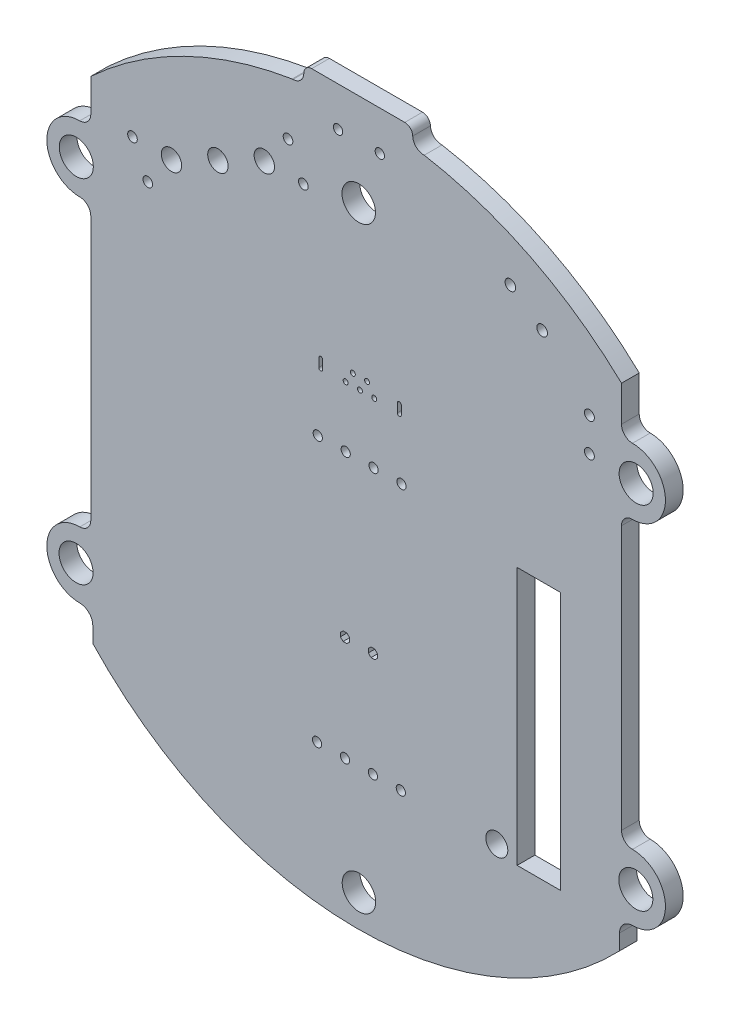
from build123d import *

# Parameters (mm, degrees)
MODEL_R             = 0.4191
MODEL_R_2           = 0.227
MODEL_R_3           = 0.482663622
MODEL_R_4           = 0.43815
MODEL_R_5           = 0.9271
MODEL_R_6           = 0.425
MODEL_R_7           = 0.45
MODEL_R_8           = 1.524
MODEL_R_9           = 1.55
MODEL_R_10          = 1
MODEL_W             = 3.937
MODEL_H             = 23.478
BOSS_EXTRUDE1_DEPTH = 1.6129


with BuildPart() as part:
    # Model → Boss-Extrude1 (new body)
    with BuildSketch(Plane.XY):
        with BuildLine():
            Line((-23.779710926, -18.809832125), (-23.779710926, -17.398832125))
            ThreePointArc((-23.779710926, -17.398832125), (-24.125617817, -16.563739016), (-24.960710926, -16.217832125))
            ThreePointArc((-24.960710926, -16.217832125), (-27.082031269, -15.339152468), (-27.960710926, -13.217832125))
            ThreePointArc((-27.960710926, -13.217832125), (-27.082031269, -11.096511781), (-24.960710926, -10.217832125))
            ThreePointArc((-24.960710926, -10.217832125), (-24.253604145, -9.924938906), (-23.960710926, -9.217832125))
            Line((-23.960710926, -9.217832125), (-23.960710926, 14.782167875))
            ThreePointArc((-23.960710926, 14.782167875), (-24.253604145, 15.489274656), (-24.960710926, 15.782167875))
            ThreePointArc((-24.960710926, 15.782167875), (-27.082031269, 16.660847532), (-27.960710926, 18.782167875))
            ThreePointArc((-27.960710926, 18.782167875), (-27.082031269, 20.903488219), (-24.960710926, 21.782167875))
            ThreePointArc((-24.960710926, 21.782167875), (-24.253604145, 22.075061094), (-23.960710926, 22.782167875))
            Line((-23.960710926, 22.782167875), (-23.960710926, 25.782167875))
            ThreePointArc((-23.960710926, 25.782167875), (-15.463875449, 31.618102481), (-5.640710926, 34.742167875))
            Line((-5.640710926, 34.742167875), (-5.560710926, 34.742167875))
            ThreePointArc((-5.560710926, 34.742167875), (-4.86774628, 35.02920323), (-4.580710926, 35.722167875))
            ThreePointArc((-4.580710926, 35.722167875), (-4.369827808, 36.231284758), (-3.860710926, 36.442167875))
            Line((-3.860710926, 36.442167875), (4.609289074, 36.442167875))
            ThreePointArc((4.609289074, 36.442167875), (5.118407802, 36.231286158), (5.32929232, 35.72216859))
            ThreePointArc((5.32929232, 35.72216859), (5.651326218, 35.014708556), (6.379288359, 34.742171121))
            ThreePointArc((6.379288359, 34.742171121), (16.019672961, 31.575717146), (24.329289074, 25.752167875))
            Line((24.329289074, 25.752167875), (24.326289074, 22.516167875))
            ThreePointArc((24.326289074, 22.516167875), (24.619182293, 21.809061094), (25.326289074, 21.516167875))
            ThreePointArc((25.326289074, 21.516167875), (27.447609418, 20.637488219), (28.326289074, 18.516167875))
            ThreePointArc((28.326289074, 18.516167875), (27.447609418, 16.394847532), (25.326289074, 15.516167875))
            ThreePointArc((25.326289074, 15.516167875), (24.619182293, 15.223274656), (24.326289074, 14.516167875))
            Line((24.326289074, 14.516167875), (24.326289074, -9.483832125))
            ThreePointArc((24.326289074, -9.483832125), (24.619182293, -10.190938906), (25.326289074, -10.483832125))
            ThreePointArc((25.326289074, -10.483832125), (27.447609418, -11.362511781), (28.326289074, -13.483832125))
            ThreePointArc((28.326289074, -13.483832125), (27.447609418, -15.605152468), (25.326289074, -16.483832125))
            ThreePointArc((25.326289074, -16.483832125), (24.491195966, -16.829739016), (24.145289074, -17.664832125))
            Line((24.145289074, -17.664832125), (24.146689074, -19.076432125))
            ThreePointArc((24.146689074, -19.076432125), (0.126168598, -29.247573474), (-23.779710926, -18.809832125))
        make_face()
        with Locations((-3.370710926, -16.372832125)):
            Circle(MODEL_R, mode=Mode.SUBTRACT)
        with Locations((-0.830710926, -16.372832125)):
            Circle(MODEL_R, mode=Mode.SUBTRACT)
        with Locations((1.709289074, -16.372832125)):
            Circle(MODEL_R, mode=Mode.SUBTRACT)
        with Locations((4.249289074, -16.372832125)):
            Circle(MODEL_R, mode=Mode.SUBTRACT)
        with Locations((4.312789074, 7.804667875)):
            Circle(MODEL_R, mode=Mode.SUBTRACT)
        with Locations((1.772789074, 7.804667875)):
            Circle(MODEL_R, mode=Mode.SUBTRACT)
        with Locations((-0.767210926, 7.804667875)):
            Circle(MODEL_R, mode=Mode.SUBTRACT)
        with Locations((-3.307210926, 7.804667875)):
            Circle(MODEL_R, mode=Mode.SUBTRACT)
        with Locations((0.530089074, 13.311767875)):
            Circle(MODEL_R_2, mode=Mode.SUBTRACT)
        with Locations((-0.119910926, 14.311767875)):
            Circle(MODEL_R_2, mode=Mode.SUBTRACT)
        with Locations((1.830089074, 13.311767875)):
            Circle(MODEL_R_2, mode=Mode.SUBTRACT)
        with Locations((1.180089074, 14.311767875)):
            Circle(MODEL_R_2, mode=Mode.SUBTRACT)
        with Locations((-0.769910926, 13.311767875)):
            Circle(MODEL_R_2, mode=Mode.SUBTRACT)
        with Locations((14.214989074, 28.432167875)):
            Circle(MODEL_R_3, mode=Mode.SUBTRACT)
        with Locations((-20.168710926, 22.918167875)):
            Circle(MODEL_R_4, mode=Mode.SUBTRACT)
        with Locations((17.107289074, 26.303367875)):
            Circle(MODEL_R_3, mode=Mode.SUBTRACT)
        with Locations((-18.776910926, 20.064467875)):
            Circle(MODEL_R_4, mode=Mode.SUBTRACT)
        with Locations((-6.014510926, 29.821667875)):
            Circle(MODEL_R_4, mode=Mode.SUBTRACT)
        with Locations((-4.622710926, 26.967967875)):
            Circle(MODEL_R_4, mode=Mode.SUBTRACT)
        with Locations((-16.619110926, 22.883167875)):
            Circle(MODEL_R_5, mode=Mode.SUBTRACT)
        with Locations((-12.395710926, 24.943067875)):
            Circle(MODEL_R_5, mode=Mode.SUBTRACT)
        with Locations((-8.172210926, 27.002967875)):
            Circle(MODEL_R_5, mode=Mode.SUBTRACT)
        with Locations((2.339289074, 32.852167875)):
            Circle(MODEL_R_6, mode=Mode.SUBTRACT)
        with Locations((-1.460710926, 32.852167875)):
            Circle(MODEL_R_6, mode=Mode.SUBTRACT)
        with Locations((21.409289074, 21.770167875)):
            Circle(MODEL_R_7, mode=Mode.SUBTRACT)
        with Locations((21.409289074, 18.734167875)):
            Circle(MODEL_R_7, mode=Mode.SUBTRACT)
        with Locations((0.419289074, 27.993767875)):
            Circle(MODEL_R_8, mode=Mode.SUBTRACT)
        with Locations((-25.280710926, 18.783767875)):
            Circle(MODEL_R_9, mode=Mode.SUBTRACT)
        with Locations((-25.300710926, -13.226232125)):
            Circle(MODEL_R_9, mode=Mode.SUBTRACT)
        with Locations((0.439289074, -26.316232125)):
            Circle(MODEL_R_8, mode=Mode.SUBTRACT)
        with Locations((25.629289074, -13.486232125)):
            Circle(MODEL_R_9, mode=Mode.SUBTRACT)
        with Locations((25.659289074, 18.523767875)):
            Circle(MODEL_R_9, mode=Mode.SUBTRACT)
        with Locations((12.982089074, -16.238232125)):
            Circle(MODEL_R_10, mode=Mode.SUBTRACT)
        with BuildLine():
            Line((-2.85875692, 14.001767875), (-2.85875692, 13.216767875))
            ThreePointArc((-2.85875692, 13.216767875), (-3.038660926, 13.03686387), (-3.218564931, 13.216767875))
            Line((-3.218564931, 13.216767875), (-3.218564931, 14.001767875))
            ThreePointArc((-3.218564931, 14.001767875), (-3.038660926, 14.181671881), (-2.85875692, 14.001767875))
        make_face(mode=Mode.SUBTRACT)
        with BuildLine():
            Line((4.29124308, 14.001767875), (4.29124308, 13.216767875))
            ThreePointArc((4.29124308, 13.216767875), (4.111339074, 13.03686387), (3.931435069, 13.216767875))
            Line((3.931435069, 13.216767875), (3.931435069, 14.001767875))
            ThreePointArc((3.931435069, 14.001767875), (4.111339074, 14.181671881), (4.29124308, 14.001767875))
        make_face(mode=Mode.SUBTRACT)
        Polygon((2.128389074, -6.674157085), (2.128389074, -7.021507165), (1.882964114, -7.266932125), (1.535614034, -7.266932125), (1.290189074, -7.021507165), (1.290189074, -6.674157085), (1.535614034, -6.428732125), (1.882964114, -6.428732125), align=None, mode=Mode.SUBTRACT)
        Polygon((-0.411610926, -6.674157085), (-0.411610926, -7.021507165), (-0.657035886, -7.266932125), (-1.004385966, -7.266932125), (-1.249810926, -7.021507165), (-1.249810926, -6.674157085), (-1.004385966, -6.428732125), (-0.657035886, -6.428732125), align=None, mode=Mode.SUBTRACT)
        with Locations((16.800789074, -5.252332125)):
            Rectangle(MODEL_W, MODEL_H, mode=Mode.SUBTRACT)
    extrude(amount=BOSS_EXTRUDE1_DEPTH)


solid = part.part
